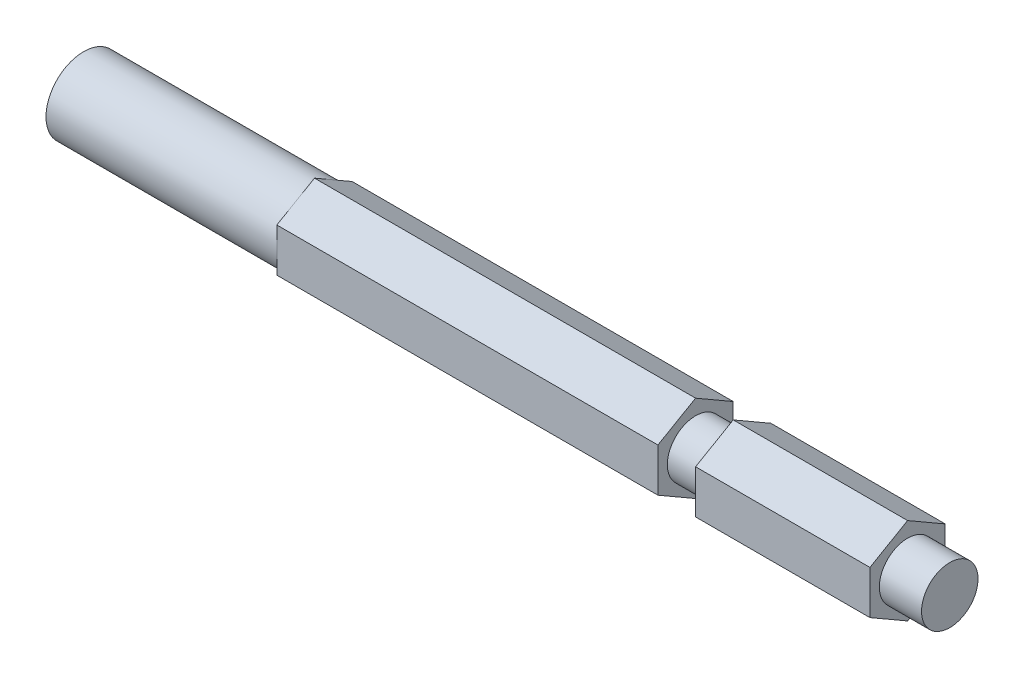
from build123d import *

# Parameters (mm, degrees)
SKETCH1_R               = 6.35
BOSS_EXTRUDE1_DEPTH     = 146.05
CUT_EXTRUDE1_DEPTH      = 1
CUT_EXTRUDE1_DEPTH_BACK = 25.4
BOSS_EXTRUDE2_START     = -7.112
BOSS_EXTRUDE2_DEPTH     = 100.0125
SKETCH5_R               = 6.35
SKETCH5_R_2             = 4.7625
CUT_EXTRUDE2_DEPTH      = 7.112
CUT_EXTRUDE3_START      = -36.5125
SKETCH6_R               = 19.82685814
SKETCH6_R_2             = 4.7625
CUT_EXTRUDE3_DEPTH      = 6.35


with BuildPart() as part:
    # Sketch1 → Boss-Extrude1 (new body)
    with BuildSketch(Plane(origin=(0, 0, 0), x_dir=(0, 0, -1), z_dir=(1, 0, 0))):
        Circle(SKETCH1_R)
    extrude(amount=BOSS_EXTRUDE1_DEPTH)

    # Sketch2 → Cut-Extrude1 (cut, two sides)
    with BuildSketch(Plane.ZY) as cut_extrude1_sk:
        Polygon((-4.826, -44.764945263), (-4.826, -4.12701151), (-4.826, 4.12701151), (-4.826, 44.764945263), (-86.101867507, 44.764945263), (-86.101867507, -44.764945263), align=None)
    extrude(amount=CUT_EXTRUDE1_DEPTH, mode=Mode.SUBTRACT)
    extrude(cut_extrude1_sk.sketch, amount=-CUT_EXTRUDE1_DEPTH_BACK, mode=Mode.SUBTRACT)

    # Sketch4 → Boss-Extrude2 (add)
    with BuildSketch(Plane(origin=(146.05, 0, 0), x_dir=(0, 0, -1), z_dir=(1, 0, 0)).offset(BOSS_EXTRUDE2_START)):
        Polygon((6.35, -3.666174209), (6.35, 3.666174209), (0, 7.332348419), (-6.35, 3.666174209), (-6.35, -3.666174209), (0, -7.332348419), align=None)
    extrude(amount=-BOSS_EXTRUDE2_DEPTH)

    # Sketch5 → Cut-Extrude2 (cut)
    with BuildSketch(Plane(origin=(146.05, 0, 0), x_dir=(0, 0, -1), z_dir=(1, 0, 0))):
        Circle(SKETCH5_R)
        Circle(SKETCH5_R_2, mode=Mode.SUBTRACT)
    extrude(amount=-CUT_EXTRUDE2_DEPTH, mode=Mode.SUBTRACT)

    # Sketch6 → Cut-Extrude3 (cut)
    with BuildSketch(Plane(origin=(146.05, 0, 0), x_dir=(0, 0, -1), z_dir=(1, 0, 0)).offset(CUT_EXTRUDE3_START)):
        Circle(SKETCH6_R)
        Circle(SKETCH6_R_2, mode=Mode.SUBTRACT)
    extrude(amount=-CUT_EXTRUDE3_DEPTH, mode=Mode.SUBTRACT)


solid = part.part
